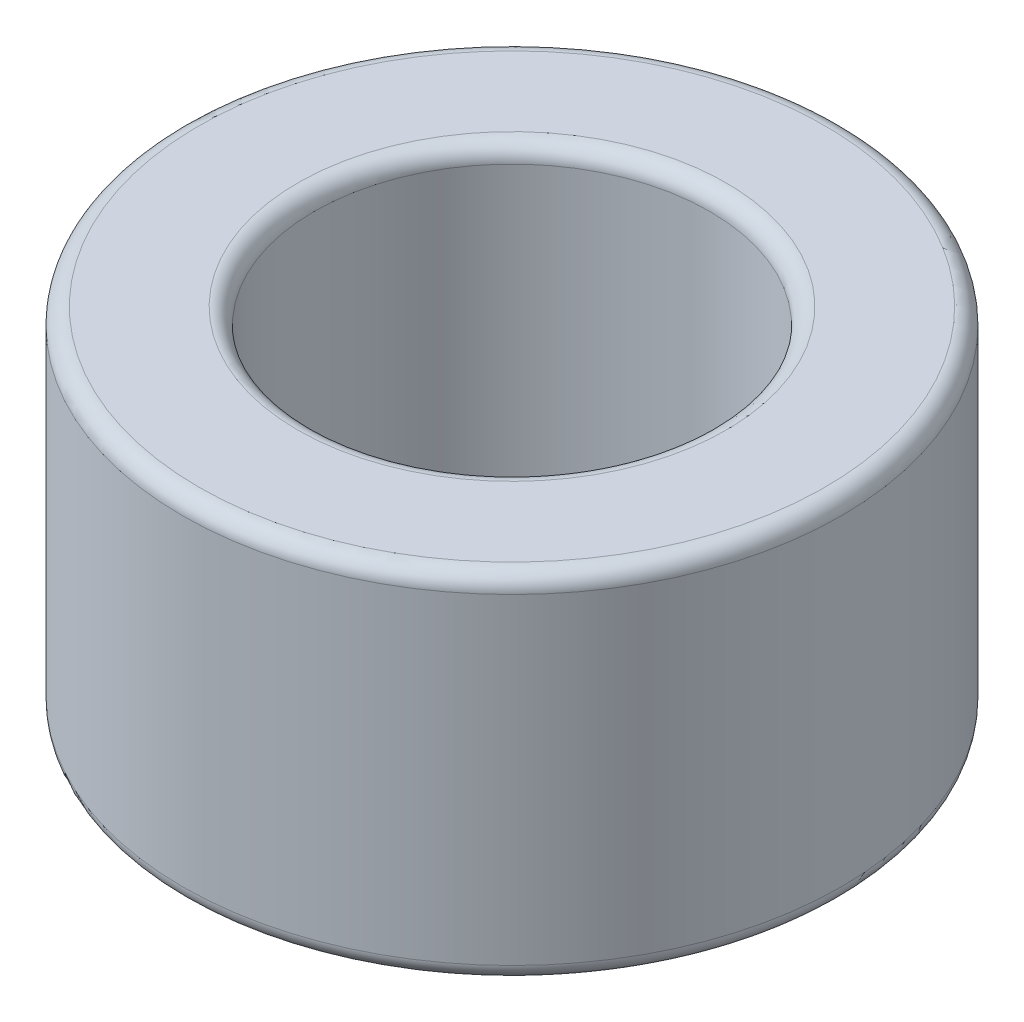
from build123d import *

# Parameters (mm, degrees)
SKETCH1_R           = 4
SKETCH1_R_2         = 2.4
BOSS_EXTRUDE1_DEPTH = 4.3
FILLET1_R           = 0.2


with BuildPart() as part:
    # Sketch1 → Boss-Extrude1 (new body)
    with BuildSketch(Plane(origin=(0, 0, 0), x_dir=(1, 0, 0), z_dir=(0, 1, 0))):
        Circle(SKETCH1_R)
        Circle(SKETCH1_R_2, mode=Mode.SUBTRACT)
    extrude(amount=BOSS_EXTRUDE1_DEPTH)

    # Fillet1
    fillet1_edges = [part.edges().sort_by_distance(p)[0] for p in [
        (-4, 0, 0),
        (-4, 4.3, 0),
        (-2.4, 0, 0),
        (-2.4, 4.3, 0),
    ]]
    fillet(fillet1_edges, radius=FILLET1_R)


solid = part.part
